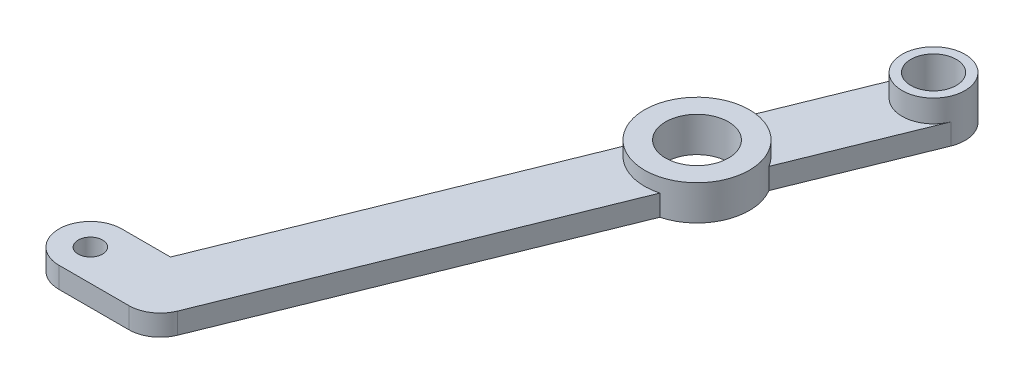
from build123d import *

# Parameters (mm, degrees)
SKETCH1_R           = 1.75
BOSS_EXTRUDE1_DEPTH = 3
BOSS_EXTRUDE2_DEPTH = 3
SKETCH3_R           = 4.5
SKETCH3_R_2         = 3.25
BOSS_EXTRUDE3_DEPTH = 3.2
SKETCH4_R           = 3.25
CUT_EXTRUDE1_DEPTH  = 3
SKETCH6_R           = 7.5
BOSS_EXTRUDE4_DEPTH = 3
SKETCH5_R           = 4.5
CUT_EXTRUDE2_DEPTH  = 7.2
SKETCH7_R           = 7.5
SKETCH7_R_2         = 4.5
BOSS_EXTRUDE5_DEPTH = 2


with BuildPart() as part:
    # Sketch1 → Boss-Extrude1 (new body)
    with BuildSketch(Plane(origin=(0, 0, 0), x_dir=(1, 0, 0), z_dir=(0, 1, 0))):
        with BuildLine():
            Line((0, -4.5), (10, -4.5))
            ThreePointArc((10, -4.5), (14.5, 0), (10, 4.5))
            Line((10, 4.5), (0, 4.5))
            ThreePointArc((0, 4.5), (-4.5, 0), (0, -4.5))
        make_face()
        Circle(SKETCH1_R, mode=Mode.SUBTRACT)
    extrude(amount=BOSS_EXTRUDE1_DEPTH)

    # Sketch2 → Boss-Extrude2 (add)
    with BuildSketch(Plane(origin=(0, 3, 0), x_dir=(1, 0, 0), z_dir=(0, 1, 0))):
        with BuildLine():
            Line((10, 0), (11.688465713, 4.171220869))
            ThreePointArc((11.688465713, 4.171220869), (10.860088975, 4.41704052), (10, 4.5))
            Line((10, 4.5), (6.96685822, 4.5))
            ThreePointArc((6.96685822, 4.5), (8.346615874, -1.181489024), (14.171220869, -1.688465713))
            Line((14.171220869, -1.688465713), (10, 0))
        make_face()
        with BuildLine():
            ThreePointArc((46.064462111, 77.10126181), (43.648814249, 74.646303405), (40.204775529, 74.618506654))
            Line((40.204775529, 74.618506654), (11.688465713, 4.171220869))
            ThreePointArc((11.688465713, 4.171220869), (14.143424118, 1.755573007), (14.171220869, -1.688465713))
            Line((14.171220869, -1.688465713), (46.064462111, 77.10126181))
        make_face()
        with BuildLine():
            ThreePointArc((14.171220869, -1.688465713), (14.143424118, 1.755573007), (11.688465713, 4.171220869))
            Line((11.688465713, 4.171220869), (10, 0))
            Line((10, 0), (14.171220869, -1.688465713))
        make_face()
        with BuildLine():
            Line((11.688465713, 4.171220869), (40.204775529, 74.618506654))
            ThreePointArc((40.204775529, 74.618506654), (37.749817124, 77.034154516), (37.722020373, 80.478193235))
            Line((37.722020373, 80.478193235), (6.96685822, 4.5))
            Line((6.96685822, 4.5), (10, 4.5))
            ThreePointArc((10, 4.5), (10.860088975, 4.41704052), (11.688465713, 4.171220869))
        make_face()
        with BuildLine():
            Line((37.722020373, 80.478193235), (41.893241242, 78.789727523))
            Line((41.893241242, 78.789727523), (46.064462111, 77.10126181))
            ThreePointArc((46.064462111, 77.10126181), (46.310281762, 77.929638548), (46.393241242, 78.789727523))
            ThreePointArc((46.393241242, 78.789727523), (42.753330217, 83.206768043), (37.722020373, 80.478193235))
        make_face()
        with BuildLine():
            Line((46.064462111, 77.10126181), (41.893241242, 78.789727523))
            Line((41.893241242, 78.789727523), (40.204775529, 74.618506654))
            ThreePointArc((40.204775529, 74.618506654), (43.648814249, 74.646303405), (46.064462111, 77.10126181))
        make_face()
        with BuildLine():
            Line((40.204775529, 74.618506654), (41.893241242, 78.789727523))
            Line((41.893241242, 78.789727523), (37.722020373, 80.478193235))
            ThreePointArc((37.722020373, 80.478193235), (37.749817124, 77.034154516), (40.204775529, 74.618506654))
        make_face()
    extrude(amount=-BOSS_EXTRUDE2_DEPTH)

    # Sketch3 → Boss-Extrude3 (add)
    with BuildSketch(Plane(origin=(0, 3, 0), x_dir=(1, 0, 0), z_dir=(0, 1, 0))):
        with Locations((41.893241242, 78.789727523)):
            Circle(SKETCH3_R)
        with Locations((41.893241242, 78.789727523)):
            Circle(SKETCH3_R_2, mode=Mode.SUBTRACT)
    extrude(amount=BOSS_EXTRUDE3_DEPTH)

    # Sketch4 → Cut-Extrude1 (cut)
    with BuildSketch(Plane(origin=(0, 3, 0), x_dir=(1, 0, 0), z_dir=(0, 1, 0))):
        with Locations((41.893241242, 78.789727523)):
            Circle(SKETCH4_R)
    extrude(amount=-CUT_EXTRUDE1_DEPTH, mode=Mode.SUBTRACT)

    # Sketch6 → Boss-Extrude4 (add)
    with BuildSketch(Plane.XZ):
        with Locations((32.137661568, -54.68934028)):
            Circle(SKETCH6_R)
    extrude(amount=-BOSS_EXTRUDE4_DEPTH)

    # Sketch5 → Cut-Extrude2 (cut, through all)
    with BuildSketch(Plane.XZ):
        with Locations((32.137661568, -54.68934028)):
            Circle(SKETCH5_R)
    extrude(amount=-CUT_EXTRUDE2_DEPTH, mode=Mode.SUBTRACT)

    # Sketch7 → Boss-Extrude5 (add)
    with BuildSketch(Plane(origin=(0, 3, 0), x_dir=(1, 0, 0), z_dir=(0, 1, 0))):
        with Locations((32.137661568, 54.68934028)):
            Circle(SKETCH7_R)
        with Locations((32.137661568, 54.68934028)):
            Circle(SKETCH7_R_2, mode=Mode.SUBTRACT)
    extrude(amount=BOSS_EXTRUDE5_DEPTH)


solid = part.part
